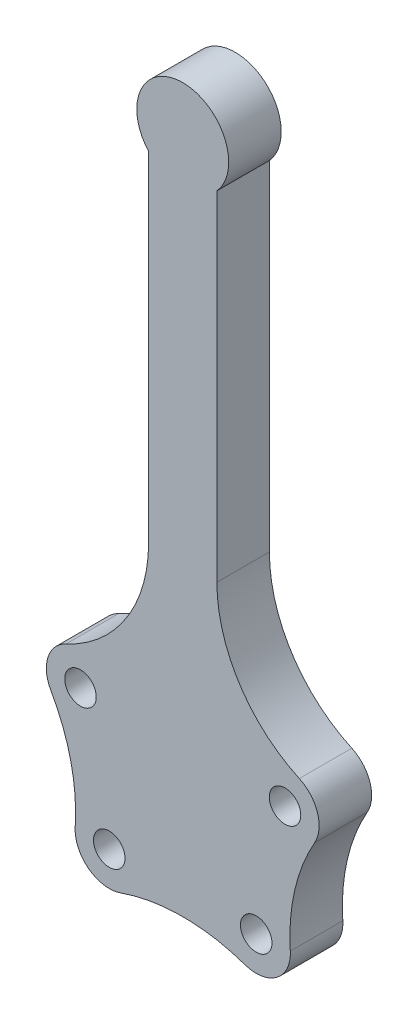
from build123d import *

# Parameters (mm, degrees)
SKETCH1_R           = 6000
BOSS_EXTRUDE2_DEPTH = 20000


with BuildPart() as part:
    # Sketch1 → Boss-Extrude2 (new body)
    with BuildSketch(Plane.XY):
        with BuildLine():
            ThreePointArc((44390.857987613, 32133.621884428), (21519.010141486, 52059.884818003), (12998.849230427, 81173.184810343))
            Line((12998.849230427, 81173.184810343), (12998.849230427, 210284.62548614))
            ThreePointArc((12998.849230427, 210284.62548614), (-1.150769573, 239500), (-13001.150769573, 210284.62548614))
            Line((-13001.150769573, 210284.62548614), (-13001.150769573, 81173.184810343))
            ThreePointArc((-13001.150769573, 81173.184810343), (-21521.311680632, 52059.884818003), (-44393.159526759, 32133.621884428))
            ThreePointArc((-44393.159526759, 32133.621884428), (-51329.065558996, 24299.0717741), (-50245.491347745, 13891.726538739))
            ThreePointArc((-50245.491347745, 13891.726538739), (-42632.774930501, -5622.749647829), (-40959.140278036, -26502.576733693))
            ThreePointArc((-40959.140278036, -26502.576733693), (-35861.506690488, -37703.954856701), (-23707.185374082, -39635.071990656))
            ThreePointArc((-23707.185374082, -39635.071990656), (-1.150769573, -35620.540462453), (23704.883834937, -39635.071990656))
            ThreePointArc((23704.883834937, -39635.071990656), (35859.205151343, -37703.954856701), (40956.83873889, -26502.576733693))
            ThreePointArc((40956.83873889, -26502.576733693), (42630.473391356, -5622.749647829), (50243.1898086, 13891.726538739))
            ThreePointArc((50243.1898086, 13891.726538739), (51326.764019851, 24299.0717741), (44390.857987613, 32133.621884428))
        make_face()
        with Locations((-27987.441622119, -27359.917961025)):
            Circle(SKETCH1_R, mode=Mode.SUBTRACT)
        with Locations((-38950.494968304, 20327.80118004)):
            Circle(SKETCH1_R, mode=Mode.SUBTRACT)
        with Locations((27985.140082973, -27359.917961025)):
            Circle(SKETCH1_R, mode=Mode.SUBTRACT)
        with Locations((38948.193429158, 20327.80118004)):
            Circle(SKETCH1_R, mode=Mode.SUBTRACT)
    extrude(amount=BOSS_EXTRUDE2_DEPTH)


solid = part.part
